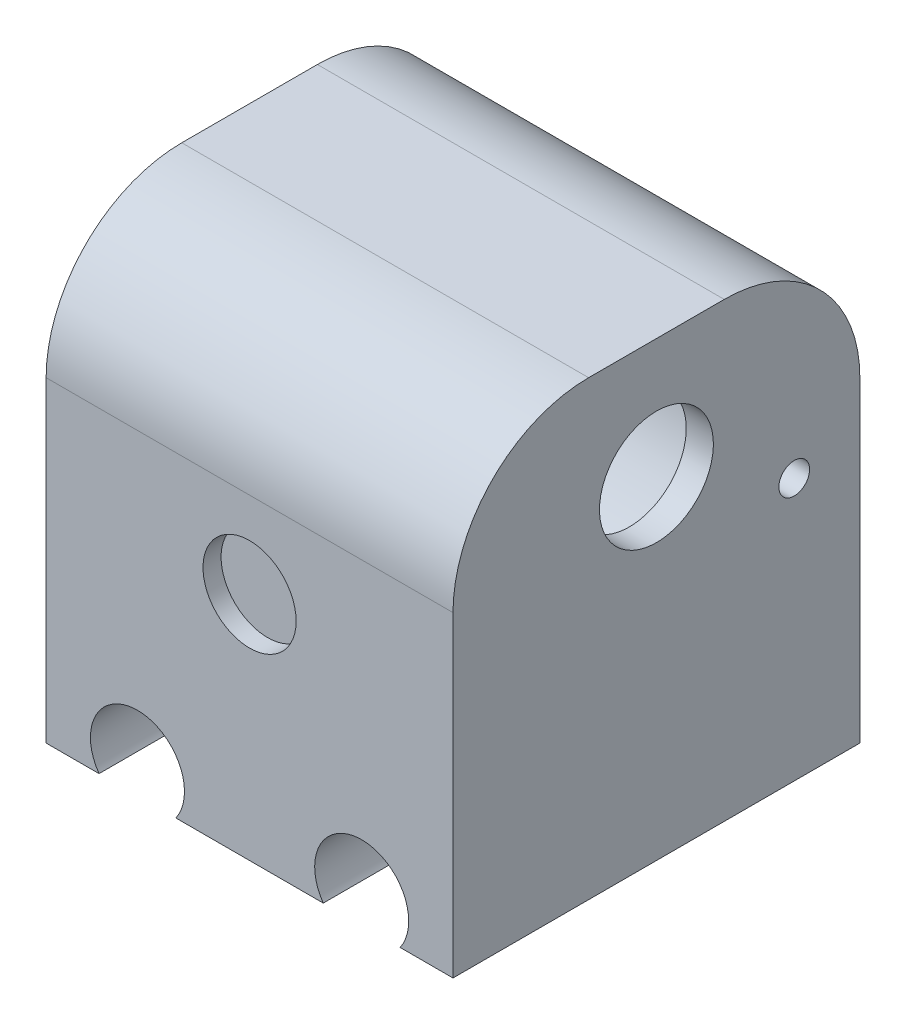
from build123d import *

# Parameters (mm, degrees)
SKETCH1_W           = 45
SKETCH1_H           = 50
BOSS_EXTRUDE1_DEPTH = 45
SKETCH2_R           = 5.2
CUT_EXTRUDE1_DEPTH  = 45
SKETCH9_R           = 5.15
CUT_EXTRUDE6_DEPTH  = 2
SKETCH10_R          = 5.15
CUT_EXTRUDE7_DEPTH  = 2
SKETCH12_R          = 18.75
CUT_EXTRUDE8_DEPTH  = 50
SKETCH13_W          = 45
SKETCH13_H          = 6.66747138
CUT_EXTRUDE9_DEPTH  = 46
SKETCH14_W          = 45
SKETCH14_H          = 6.66747138
BOSS_EXTRUDE2_DEPTH = 45
SKETCH15_R          = 18.375
CUT_EXTRUDE10_DEPTH = 45
FILLET1_R           = 15
SKETCH16_R          = 18.75
BOSS_EXTRUDE3_DEPTH = 2
SKETCH18_R          = 18.75
CUT_EXTRUDE11_DEPTH = 43
SKETCH19_R          = 6.3
CUT_EXTRUDE12_DEPTH = 43
SKETCH20_R          = 1.7
CUT_EXTRUDE13_DEPTH = 43
SKETCH21_R          = 20
SKETCH21_R_2        = 18.75
BOSS_EXTRUDE4_DEPTH = 7
SKETCH22_R          = 18.75
SKETCH22_R_2        = 1.7
SKETCH22_R_3        = 6.3
BOSS_EXTRUDE5_DEPTH = 7
SKETCH23_R          = 18.75
SKETCH23_R_2        = 1.7
SKETCH23_R_3        = 6.3
CUT_EXTRUDE14_DEPTH = 7
SKETCH24_R          = 1.7
CUT_EXTRUDE15_DEPTH = 5
BOSS_EXTRUDE6_DEPTH = 2
SKETCH26_R          = 20
SKETCH26_R_2        = 6.3
SKETCH26_R_3        = 1.7
BOSS_EXTRUDE7_DEPTH = 10
SKETCH27_R          = 20
CUT_EXTRUDE16_DEPTH = 7


with BuildPart() as part:
    # Sketch1 → Boss-Extrude1 (new body)
    with BuildSketch(Plane.XY):
        with Locations((8.236607143, -2.901785714)):
            Rectangle(SKETCH1_W, SKETCH1_H)
    extrude(amount=BOSS_EXTRUDE1_DEPTH)

    # Sketch2 → Cut-Extrude1 (cut)
    with BuildSketch(Plane.XY.offset(45)):
        with Locations((-4.163392857, -24.901785714)):
            Circle(SKETCH2_R)
        with Locations((20.636607143, -24.901785714)):
            Circle(SKETCH2_R)
    extrude(amount=-CUT_EXTRUDE1_DEPTH, mode=Mode.SUBTRACT)

    # Sketch9 → Cut-Extrude6 (cut)
    with BuildSketch(Plane.XY.offset(45)):
        with Locations((8.236607143, -2.401785714)):
            Circle(SKETCH9_R)
    extrude(amount=-CUT_EXTRUDE6_DEPTH, mode=Mode.SUBTRACT)

    # Sketch10 → Cut-Extrude7 (cut)
    with BuildSketch(Plane(origin=(0, 0, 0), x_dir=(-1, 0, 0), z_dir=(0, 0, -1))):
        with Locations((-8.236607143, -2.401785714)):
            Circle(SKETCH10_R)
    extrude(amount=-CUT_EXTRUDE7_DEPTH, mode=Mode.SUBTRACT)

    # Sketch12 → Cut-Extrude8 (cut)
    with BuildSketch(Plane.ZY.offset(14.263392857)):
        with Locations((22.5, 1.098214286)):
            Circle(SKETCH12_R)
    extrude(amount=-CUT_EXTRUDE8_DEPTH, mode=Mode.SUBTRACT)

    # Sketch13 → Cut-Extrude9 (cut)
    with BuildSketch(Plane.ZY.offset(14.263392857)):
        with Locations((22.5, 18.764478596)):
            Rectangle(SKETCH13_W, SKETCH13_H)
    extrude(amount=-CUT_EXTRUDE9_DEPTH, mode=Mode.SUBTRACT)

    # Sketch14 → Boss-Extrude2 (add)
    with BuildSketch(Plane.ZY.offset(14.263392857)):
        with Locations((22.5, 18.764478596)):
            Rectangle(SKETCH14_W, SKETCH14_H)
    extrude(amount=-BOSS_EXTRUDE2_DEPTH)

    # Sketch15 → Cut-Extrude10 (cut)
    with BuildSketch(Plane.ZY.offset(14.263392857)):
        with Locations((22.5, 1.098214286)):
            Circle(SKETCH15_R)
    extrude(amount=-CUT_EXTRUDE10_DEPTH, mode=Mode.SUBTRACT)

    # Fillet1
    fillet1_edges = [part.edges().sort_by_distance(p)[0] for p in [
        (8.236607143, 22.098214286, 0),
        (8.236607143, 22.098214286, 45),
    ]]
    fillet(fillet1_edges, radius=FILLET1_R)

    # Sketch16 → Boss-Extrude3 (add)
    with BuildSketch(Plane(origin=(30.736607143, 0, 0), x_dir=(0, 0, -1), z_dir=(1, 0, 0))):
        with Locations((-22.5, 1.098214286)):
            Circle(SKETCH16_R)
    extrude(amount=-BOSS_EXTRUDE3_DEPTH)

    # Sketch18 → Cut-Extrude11 (cut)
    with BuildSketch(Plane.ZY.offset(14.263392857)):
        with Locations((22.5, 1.098214286)):
            Circle(SKETCH18_R)
    extrude(amount=-CUT_EXTRUDE11_DEPTH, mode=Mode.SUBTRACT)

    # Sketch19 → Cut-Extrude12 (cut)
    with BuildSketch(Plane(origin=(30.736607143, 0, 0), x_dir=(0, 0, -1), z_dir=(1, 0, 0))):
        with Locations((-22.5, 8.848214286)):
            Circle(SKETCH19_R)
    extrude(amount=-CUT_EXTRUDE12_DEPTH, mode=Mode.SUBTRACT)

    # Sketch20 → Cut-Extrude13 (cut)
    with BuildSketch(Plane(origin=(30.736607143, 0, 0), x_dir=(0, 0, -1), z_dir=(1, 0, 0))):
        with Locations((-6.05, 1.098214286)):
            Circle(SKETCH20_R)
    extrude(amount=-CUT_EXTRUDE13_DEPTH, mode=Mode.SUBTRACT)

    # Sketch21 → Boss-Extrude4 (add)
    with BuildSketch(Plane(origin=(30.736607143, 0, 0), x_dir=(0, 0, -1), z_dir=(1, 0, 0))):
        with Locations((-22.5, 1.098214286)):
            Circle(SKETCH21_R)
        with Locations((-22.5, 1.098214286)):
            Circle(SKETCH21_R_2, mode=Mode.SUBTRACT)
    extrude(amount=BOSS_EXTRUDE4_DEPTH)

    # Sketch22 → Boss-Extrude5 (add)
    with BuildSketch(Plane(origin=(30.736607143, 0, 0), x_dir=(0, 0, -1), z_dir=(1, 0, 0))):
        with Locations((-22.5, 1.098214286)):
            Circle(SKETCH22_R)
        with Locations((-6.05, 1.098214286)):
            Circle(SKETCH22_R_2, mode=Mode.SUBTRACT)
        with Locations((-22.5, 8.848214286)):
            Circle(SKETCH22_R_3, mode=Mode.SUBTRACT)
    extrude(amount=BOSS_EXTRUDE5_DEPTH)

    # Sketch23 → Cut-Extrude14 (cut)
    with BuildSketch(Plane.ZY.offset(-28.736607143)):
        with Locations((22.5, 1.098214286)):
            Circle(SKETCH23_R)
        with Locations((6.05, 1.098214286)):
            Circle(SKETCH23_R_2, mode=Mode.SUBTRACT)
        with Locations((22.5, 8.848214286)):
            Circle(SKETCH23_R_3, mode=Mode.SUBTRACT)
    extrude(amount=-CUT_EXTRUDE14_DEPTH, mode=Mode.SUBTRACT)

    # Sketch24 → Cut-Extrude15 (cut)
    with BuildSketch(Plane(origin=(37.736607143, 0, 0), x_dir=(0, 0, -1), z_dir=(1, 0, 0))):
        with Locations((-7.25882025, 1.098214286)):
            Circle(SKETCH24_R)
    extrude(amount=-CUT_EXTRUDE15_DEPTH, mode=Mode.SUBTRACT)

    # Sketch25 → Boss-Extrude6 (add)
    with BuildSketch(Plane(origin=(37.736607143, 0, 0), x_dir=(0, 0, -1), z_dir=(1, 0, 0))):
        with BuildLine():
            ThreePointArc((-6.654410125, 2.687141094), (-5.859267248, 2.063227961), (-5.55882025, 1.098214286))
            ThreePointArc((-5.55882025, 1.098214286), (-5.859267248, 0.13320061), (-6.654410125, -0.490712522))
            ThreePointArc((-6.654410125, -0.490712522), (-4.35, 1.098214286), (-6.654410125, 2.687141094))
        make_face()
    extrude(amount=-BOSS_EXTRUDE6_DEPTH)

    # Sketch26 → Boss-Extrude7 (add)
    with BuildSketch(Plane(origin=(37.736607143, 0, 0), x_dir=(0, 0, -1), z_dir=(1, 0, 0))):
        with Locations((-22.5, 1.098214286)):
            Circle(SKETCH26_R)
        with Locations((-22.5, 8.848214286)):
            Circle(SKETCH26_R_2, mode=Mode.SUBTRACT)
        with Locations((-7.25882025, 1.098214286)):
            Circle(SKETCH26_R_3, mode=Mode.SUBTRACT)
    extrude(amount=-BOSS_EXTRUDE7_DEPTH)

    # Sketch27 → Cut-Extrude16 (cut)
    with BuildSketch(Plane(origin=(37.736607143, 0, 0), x_dir=(0, 0, -1), z_dir=(1, 0, 0))):
        with Locations((-22.5, 1.098214286)):
            Circle(SKETCH27_R)
    extrude(amount=-CUT_EXTRUDE16_DEPTH, mode=Mode.SUBTRACT)


solid = part.part
